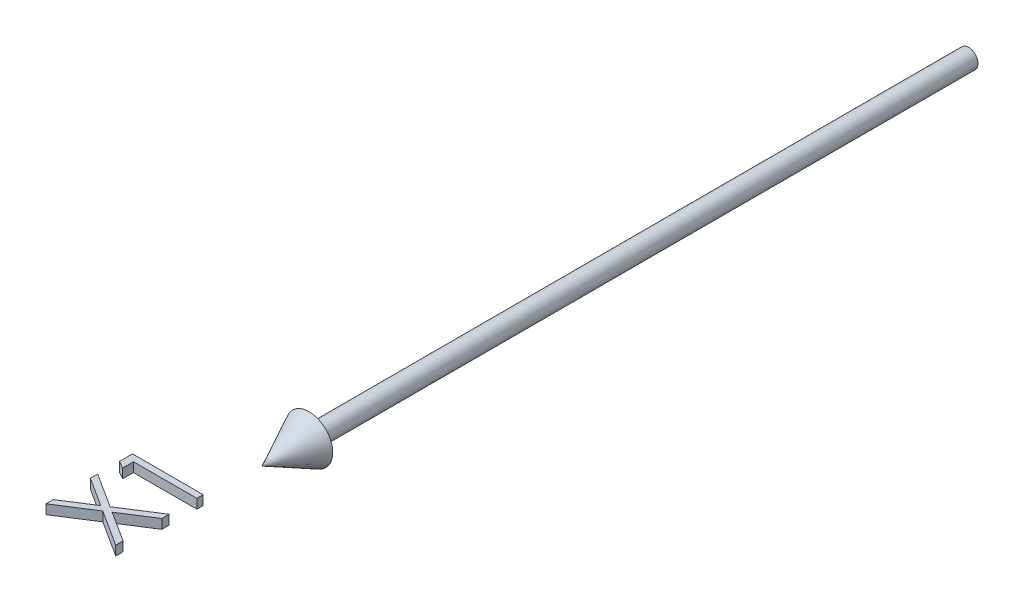
from build123d import *

# Parameters (mm, degrees)
BOSS_EXTRUDE1_DEPTH        = 1
BOSS_EXTRUDE1_DEPTH_BACK   = 1
BOSS_EXTRUDE1_2_DEPTH      = 1
BOSS_EXTRUDE1_2_DEPTH_BACK = 1


with BuildPart() as part:
    # Sketch2 → Revolve1 (revolve)
    with BuildSketch(Plane(origin=(0, 0, 0), x_dir=(1, 0, 0), z_dir=(0, 1, 0))):
        Polygon((0, -150), (5, -140), (2, -140), (2, 0), (0, 0), align=None)
    revolve(axis=Axis((0, 0, -41.949952025), (0, 0, 1)))


with BuildPart() as body_2:
    # Sketch3 → Boss-Extrude1 (new, two sides: drawn at the far end of the back side and taken through both)
    with BuildSketch(Plane(origin=(0, 0, 0), x_dir=(1, 0, 0), z_dir=(0, 1, 0)).offset(-BOSS_EXTRUDE1_DEPTH_BACK)):
        Polygon((-15, -165.2734375), (-15, -162.5), (0, -162.5), (0, -163.846153846), (-13.461538462, -163.846153846), (-13.461538462, -166.153846154), align=None)
    extrude(amount=BOSS_EXTRUDE1_DEPTH + BOSS_EXTRUDE1_DEPTH_BACK)


with BuildPart() as body_3:
    # Sketch3 → Boss-Extrude1 2 (new, two sides: drawn at the far end of the back side and taken through both)
    with BuildSketch(Plane(origin=(0, 0, 0), x_dir=(1, 0, 0), z_dir=(0, 1, 0)).offset(-BOSS_EXTRUDE1_2_DEPTH_BACK)):
        Polygon((-15, -180.865384615), (-15, -179.311899038), (-8.864182692, -175.384615385), (-15, -171.457331731), (-15, -169.903846154), (-7.650240385, -174.606370192), (0, -169.711538462), (0, -171.265024038), (-6.436298077, -175.384615385), (0, -179.504206731), (0, -181.057692308), (-7.650240385, -176.159855769), align=None)
    extrude(amount=BOSS_EXTRUDE1_2_DEPTH + BOSS_EXTRUDE1_2_DEPTH_BACK)


solid = Compound([part.part, body_2.part, body_3.part])
